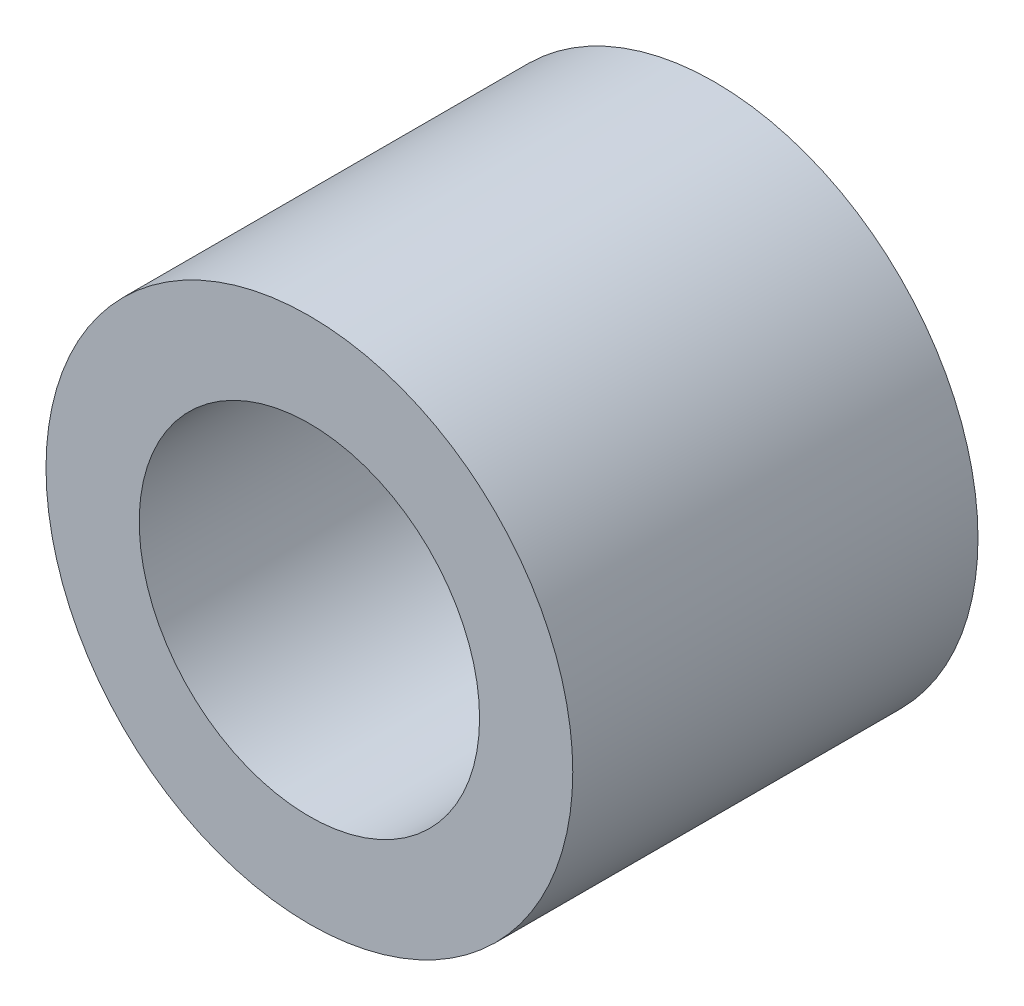
from build123d import *

# Parameters (mm, degrees)
ESQUISSE1_R        = 3.25
BOSS_EXTRU_1_DEPTH = 1
BOSS_EXTRU_2_START = 4
ESQUISSE1_3_R      = 3.25
ESQUISSE1_3_R_2    = 2.1
BOSS_EXTRU_2_DEPTH = 4


with BuildPart() as part:
    # Esquisse1 → Boss.-Extru.1 (new body)
    with BuildSketch(Plane.XY):
        Circle(ESQUISSE1_R)
    extrude(amount=-BOSS_EXTRU_1_DEPTH)

    # Esquisse1_3 → Boss.-Extru.2 (add)
    with BuildSketch(Plane.XY.offset(BOSS_EXTRU_2_START)):
        Circle(ESQUISSE1_3_R)
        Circle(ESQUISSE1_3_R_2, mode=Mode.SUBTRACT)
    extrude(amount=-BOSS_EXTRU_2_DEPTH)


solid = part.part
